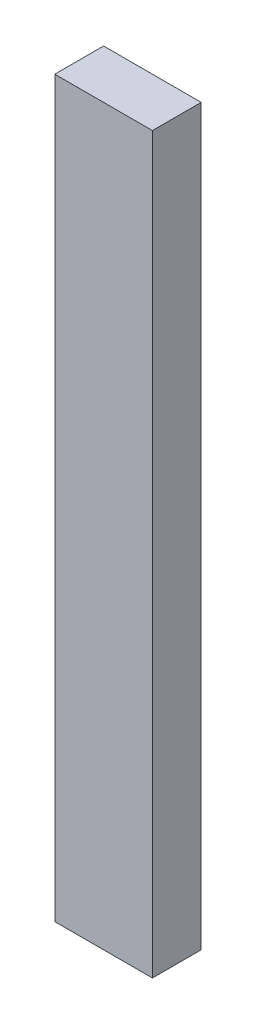
from build123d import *

# Parameters (mm, degrees)
SKETCH1_W           = 101.6
SKETCH1_H           = 763.794
BOSS_EXTRUDE1_DEPTH = 25.4


with BuildPart() as part:
    # Sketch1 → Boss-Extrude1 (new body, symmetric)
    with BuildSketch(Plane.XY):
        with Locations((50.8, 381.897)):
            Rectangle(SKETCH1_W, SKETCH1_H)
    extrude(amount=BOSS_EXTRUDE1_DEPTH, both=True)


solid = part.part
